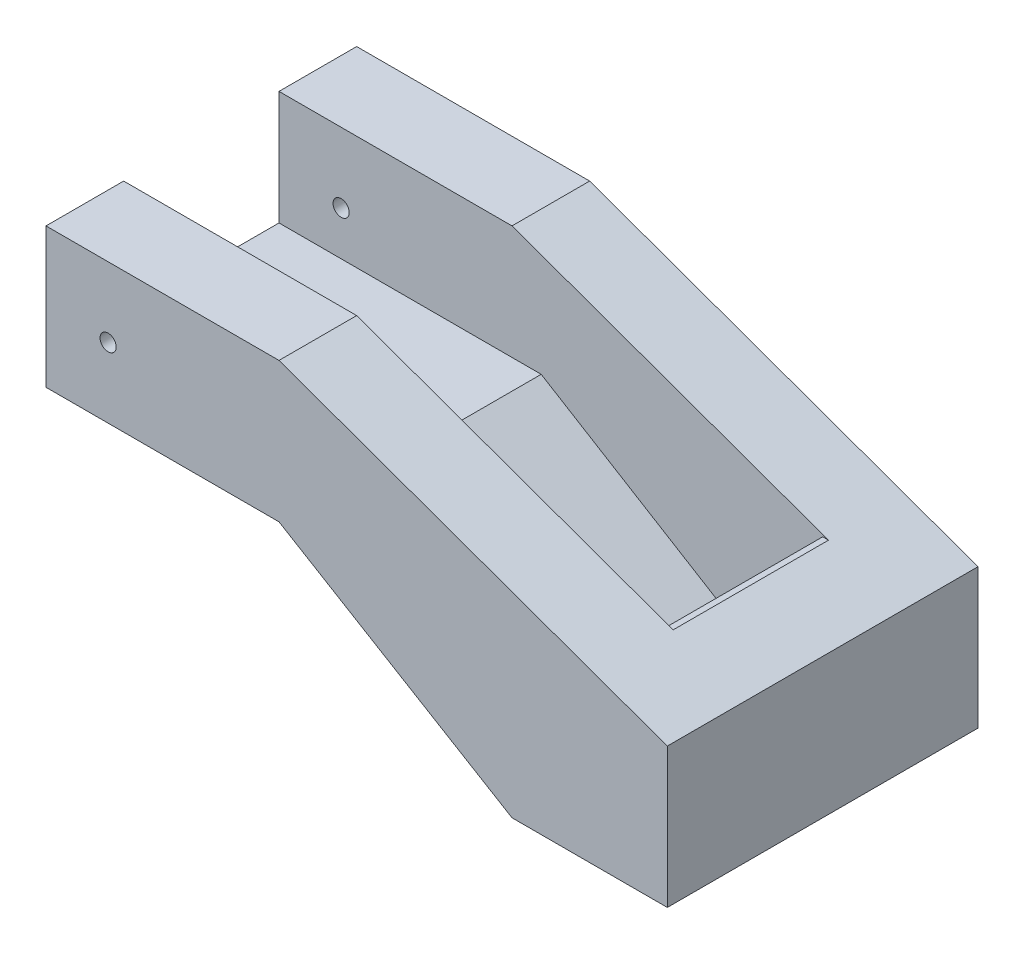
from build123d import *

# Parameters (mm, degrees)
SKETCH1_W               = 508
SKETCH1_H               = 228.6
BOSS_EXTRUDE1_DEPTH     = 254
SKETCH2_W               = 127
SKETCH2_H               = 93.154290468
CUT_EXTRUDE1_DEPTH      = 509
CUT_EXTRUDE2_DEPTH      = 254
SKETCH7_W               = 127
SKETCH7_H               = 101.6
CUT_EXTRUDE3_DEPTH      = 127
CUT_EXTRUDE5_DEPTH      = 127
CUT_EXTRUDE5_DEPTH_BACK = 0.254
SKETCH24_W              = 127
SKETCH24_H              = 101.6
BOSS_EXTRUDE3_DEPTH     = 63.5
CUT_EXTRUDE7_DEPTH      = 315.976
SKETCH27_R              = 6.604
CUT_EXTRUDE8_DEPTH      = 315.976


with BuildPart() as part:
    # Sketch1 → Boss-Extrude1 (new body)
    with BuildSketch(Plane.XY):
        Rectangle(SKETCH1_W, SKETCH1_H)
    extrude(amount=BOSS_EXTRUDE1_DEPTH)

    # Sketch2 → Cut-Extrude1 (cut, through all)
    with BuildSketch(Plane.ZY.offset(254)):
        with Locations((127, 67.722854766)):
            Rectangle(SKETCH2_W, SKETCH2_H)
    extrude(amount=-CUT_EXTRUDE1_DEPTH, mode=Mode.SUBTRACT)

    # Sketch5 → Cut-Extrude2 (cut)
    with BuildSketch(Plane.XY.offset(254)):
        Polygon((-254, 0), (-254, -114.3), (127, -114.3), (-63.5, 0), align=None)
    extrude(amount=-CUT_EXTRUDE2_DEPTH, mode=Mode.SUBTRACT)

    # Sketch7 → Cut-Extrude3 (cut)
    with BuildSketch(Plane(origin=(254, 0, 0), x_dir=(0, 0, -1), z_dir=(1, 0, 0))):
        with Locations((-127, -29.654290468)):
            Rectangle(SKETCH7_W, SKETCH7_H)
    extrude(amount=-CUT_EXTRUDE3_DEPTH, mode=Mode.SUBTRACT)

    # Sketch20 → Cut-Extrude5 (cut, two sides)
    with BuildSketch(Plane(origin=(0, 0, 190.5), x_dir=(-1, 0, 0), z_dir=(0, 0, -1))) as cut_extrude5_sk:
        Polygon((-127, 21.145709532), (39.624, 21.145709532), (-127, -80.454290468), align=None)
    extrude(amount=CUT_EXTRUDE5_DEPTH, mode=Mode.SUBTRACT)
    extrude(cut_extrude5_sk.sketch, amount=-CUT_EXTRUDE5_DEPTH_BACK, mode=Mode.SUBTRACT)

    # Sketch24 → Boss-Extrude3 (add)
    with BuildSketch(Plane(origin=(254, 0, 0), x_dir=(0, 0, -1), z_dir=(1, 0, 0))):
        with Locations((-127, -29.654290468)):
            Rectangle(SKETCH24_W, SKETCH24_H)
    extrude(amount=-BOSS_EXTRUDE3_DEPTH)

    # Sketch26 → Cut-Extrude7 (cut)
    with BuildSketch(Plane.XY.offset(254)):
        Polygon((254, 114.3), (-63.5, 114.3), (254, 0), align=None)
    extrude(amount=-CUT_EXTRUDE7_DEPTH, mode=Mode.SUBTRACT)

    # Sketch27 → Cut-Extrude8 (cut)
    with BuildSketch(Plane.XY.offset(254)):
        with Locations((-203.2, 57.15)):
            Circle(SKETCH27_R)
    extrude(amount=-CUT_EXTRUDE8_DEPTH, mode=Mode.SUBTRACT)


solid = part.part
